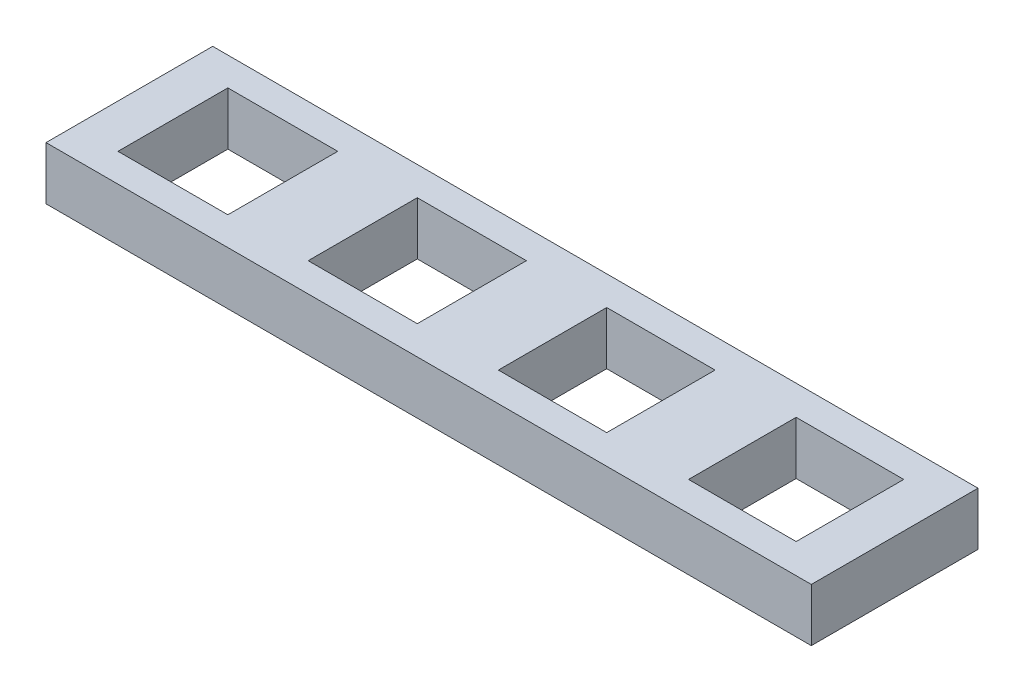
from build123d import *

# Parameters (mm, degrees)
SKETCH3_W           = 101
SKETCH3_H           = 22
SKETCH3_W_2         = 14.5
SKETCH3_H_2         = 14.5
SKETCH3_W_3         = 14.4
SKETCH3_H_3         = 14.4
SKETCH3_W_4         = 14.3
SKETCH3_H_4         = 14.3
SKETCH3_W_5         = 14.2
SKETCH3_H_5         = 14.2
BOSS_EXTRUDE5_DEPTH = 7


with BuildPart() as part:
    # Sketch3 → Boss-Extrude5 (new body)
    with BuildSketch(Plane(origin=(0, 0, 0), x_dir=(1, 0, 0), z_dir=(0, 1, 0))):
        with Locations((50.5, 11)):
            Rectangle(SKETCH3_W, SKETCH3_H)
        with Locations((13, 11)):
            Rectangle(SKETCH3_W_2, SKETCH3_H_2, mode=Mode.SUBTRACT)
        with Locations((38, 11)):
            Rectangle(SKETCH3_W_3, SKETCH3_H_3, mode=Mode.SUBTRACT)
        with Locations((63, 11)):
            Rectangle(SKETCH3_W_4, SKETCH3_H_4, mode=Mode.SUBTRACT)
        with Locations((88, 11)):
            Rectangle(SKETCH3_W_5, SKETCH3_H_5, mode=Mode.SUBTRACT)
    extrude(amount=BOSS_EXTRUDE5_DEPTH)


solid = part.part
